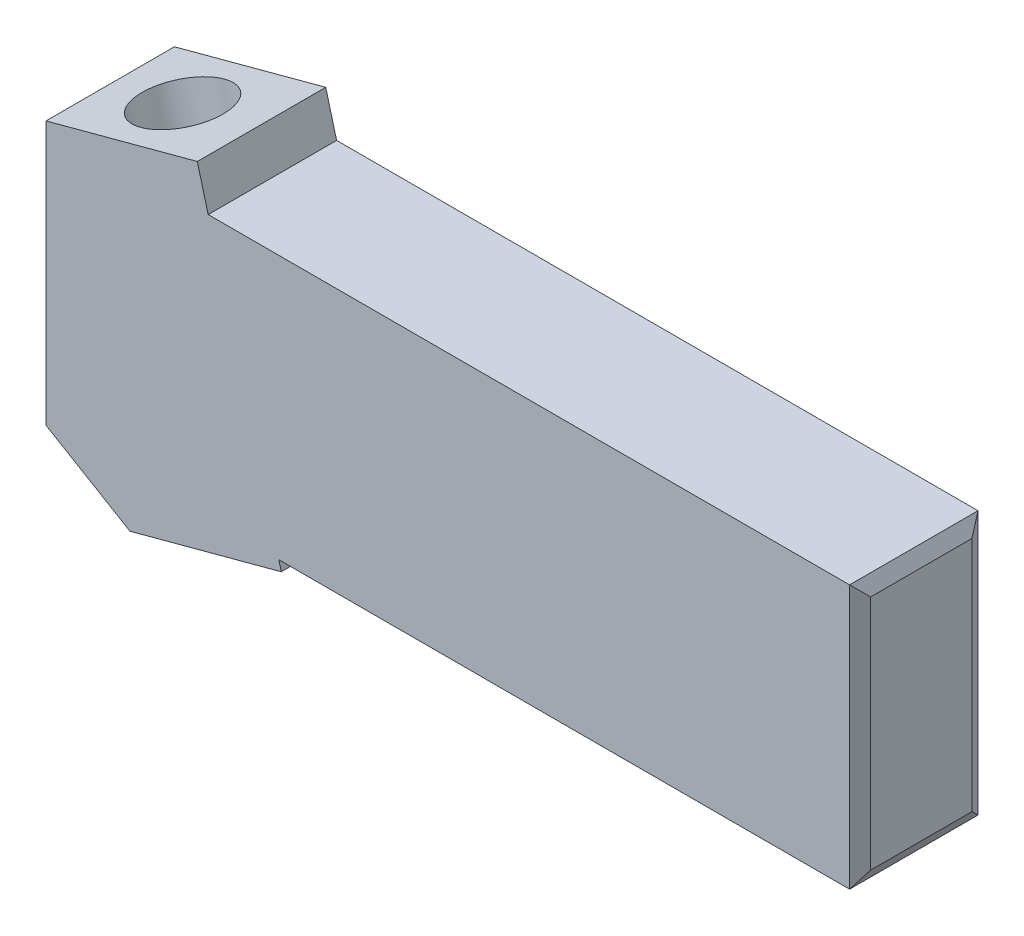
from build123d import *

# Parameters (mm, degrees)
SKETCH1_W           = 60
SKETCH1_H           = 9.5
BOSS_EXTRUDE1_DEPTH = 9.5
SKETCH4_W           = 11.588990026
SKETCH4_H           = 9.5
BOSS_EXTRUDE2_DEPTH = 24
SKETCH1_2_W         = 60
SKETCH1_2_H         = 9.5
BOSS_EXTRUDE3_DEPTH = 10
SKETCH7_R           = 3.1
CUT_EXTRUDE2_DEPTH  = 68.001533929
BOSS_EXTRUDE7_DEPTH = 9.5
CHAMFER1_SIZE       = 1
CHAMFER1_SIZE2      = 0.554309051


with BuildPart() as part:
    # Sketch1 → Boss-Extrude1 (new body)
    with BuildSketch(Plane(origin=(0, 0, 0), x_dir=(1, 0, 0), z_dir=(0, 1, 0))):
        with Locations((30, 4.75)):
            Rectangle(SKETCH1_W, SKETCH1_H)
    extrude(amount=BOSS_EXTRUDE1_DEPTH)

    # Sketch4 → Boss-Extrude2 (add)
    with BuildSketch(Plane(origin=(-2.375, 8.863620668, 0), x_dir=(0.9659258262890679, 0.2588190451025225, 0), z_dir=(-0.2588190451025225, 0.9659258262890679, 0))):
        with Locations((8.253275941, 4.75)):
            Rectangle(SKETCH4_W, SKETCH4_H)
    extrude(amount=-BOSS_EXTRUDE2_DEPTH)

    # Sketch1_2 → Boss-Extrude3 (add)
    with BuildSketch(Plane(origin=(0, 0, 0), x_dir=(1, 0, 0), z_dir=(0, 1, 0))):
        with Locations((30, 4.75)):
            Rectangle(SKETCH1_2_W, SKETCH1_2_H)
    extrude(amount=-BOSS_EXTRUDE3_DEPTH)

    # Sketch7 → Cut-Extrude2 (cut, through all)
    with BuildSketch(Plane(origin=(-2.375, 8.863620668, 0), x_dir=(0.9659258262890679, 0.25881904510252246, 0), z_dir=(-0.25881904510252246, 0.9659258262890679, 0))):
        with Locations((8, 4.75)):
            Circle(SKETCH7_R)
    extrude(amount=-CUT_EXTRUDE2_DEPTH, mode=Mode.SUBTRACT)

    # Sketch13 → Boss-Extrude7 (add)
    with BuildSketch(Plane(origin=(0, 0, -9.5), x_dir=(-1, 0, 0), z_dir=(0, 0, -1))):
        Polygon((-6.211657082, -13.682219831), (0, -10), (-5.225009252, -10), align=None)
    extrude(amount=-BOSS_EXTRUDE7_DEPTH)

    # Chamfer1
    chamfer1_edges = [part.edges().sort_by_distance(p)[0] for p in [
        (60, 9.5, -4.75),
        (60, -0.25, 0),
        (60, -10, -4.75),
        (60, -0.25, -9.5),
    ]]
    chamfer1_side = [part.faces().sort_by_distance(p)[0] for p in [
        (60, -0.25, -4.75),
    ]]
    chamfer(chamfer1_edges, length=CHAMFER1_SIZE, length2=CHAMFER1_SIZE2, reference=chamfer1_side[0])


solid = part.part
